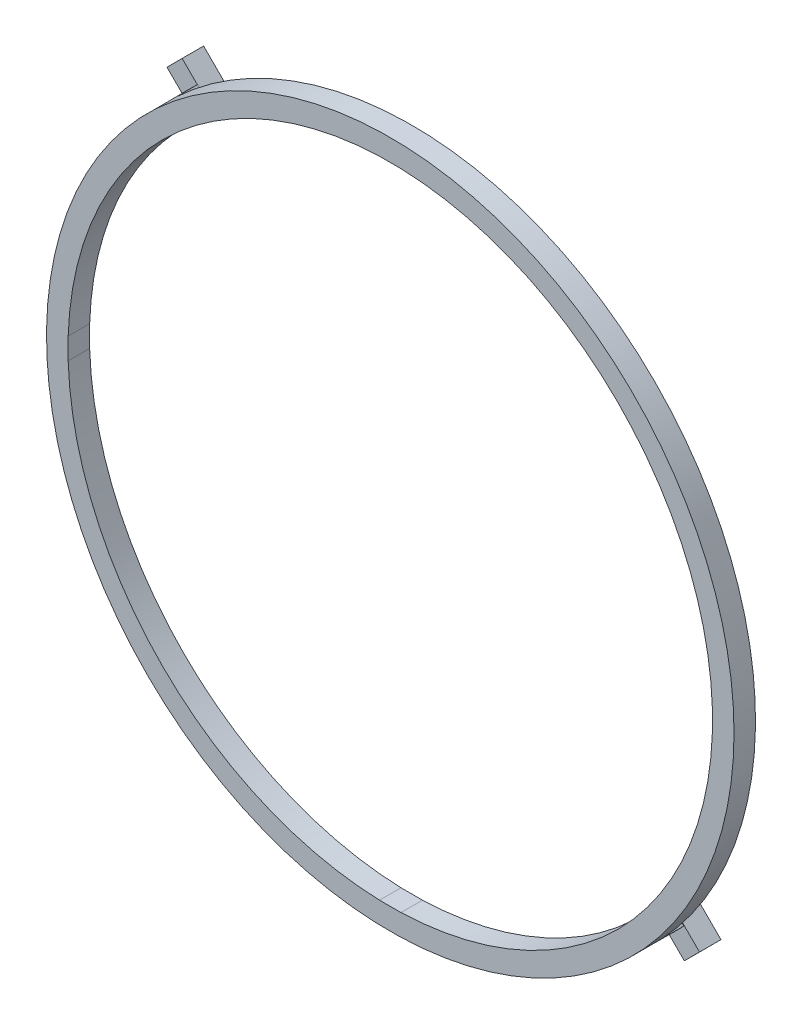
from build123d import *

# Parameters (mm, degrees)
SKETCH5_R           = 16
BOSS_EXTRUDE1_DEPTH = 1
BOSS_EXTRUDE7_DEPTH = 1
BOSS_EXTRUDE8_DEPTH = 1
CIRPATTERN1_COUNT   = 2


with BuildPart() as part:
    # Sketch5 → Boss-Extrude1 (new body)
    with BuildSketch(Plane.XY):
        Circle(SKETCH5_R)
        with BuildLine():
            Line((-0.5, -14.991664351), (0.5, -14.991664351))
            ThreePointArc((0.5, -14.991664351), (10.606601718, -10.606601718), (14.991664351, -0.5))
            Line((14.991664351, -0.5), (14.991664351, 0.5))
            ThreePointArc((14.991664351, 0.5), (10.606601718, 10.606601718), (0.5, 14.991664351))
            Line((0.5, 14.991664351), (-0.5, 14.991664351))
            ThreePointArc((-0.5, 14.991664351), (-10.606601718, 10.606601718), (-14.991664351, 0.5))
            Line((-14.991664351, 0.5), (-14.991664351, -0.5))
            ThreePointArc((-14.991664351, -0.5), (-10.606601718, -10.606601718), (-0.5, -14.991664351))
        make_face(mode=Mode.SUBTRACT)
    extrude(amount=BOSS_EXTRUDE1_DEPTH)

    # Sketch6 → Boss-Extrude7 (add)
    with BuildSketch(Plane.XY):
        with BuildLine():
            Line((-11.661770518, 10.954593027), (-10.97567443, 10.224214923))
            ThreePointArc((-10.97567443, 10.224214923), (-10.628744174, 10.58441294), (-10.269999326, 10.932845642))
            Line((-10.269999326, 10.932845642), (-10.954665948, 11.661702018))
            ThreePointArc((-10.954665948, 11.661702018), (-11.313743872, 11.313673126), (-11.661770518, 10.954593027))
        make_face()
    boss_extrude7 = extrude(amount=-BOSS_EXTRUDE7_DEPTH)

    # Sketch8 → Boss-Extrude8 (add)
    with BuildSketch(Plane(origin=(0, 0, -1), x_dir=(-1, 0, 0), z_dir=(0, 0, -1))):
        Polygon((10.97567443, 10.224214923), (10.269999326, 10.932845642), (11.687165216, 12.344100701), (12.39284032, 11.635469982), align=None)
    boss_extrude8 = extrude(amount=BOSS_EXTRUDE8_DEPTH)

    # CirPattern1: Boss-Extrude7, Boss-Extrude8 ×2 about axis
    cirpattern1_axis = Axis((0, 0, 0), (0, 0, 1))
    for i in range(1, CIRPATTERN1_COUNT):
        add(boss_extrude7.rotate(cirpattern1_axis, i * 360 / CIRPATTERN1_COUNT))
        add(boss_extrude8.rotate(cirpattern1_axis, i * 360 / CIRPATTERN1_COUNT))


solid = part.part
